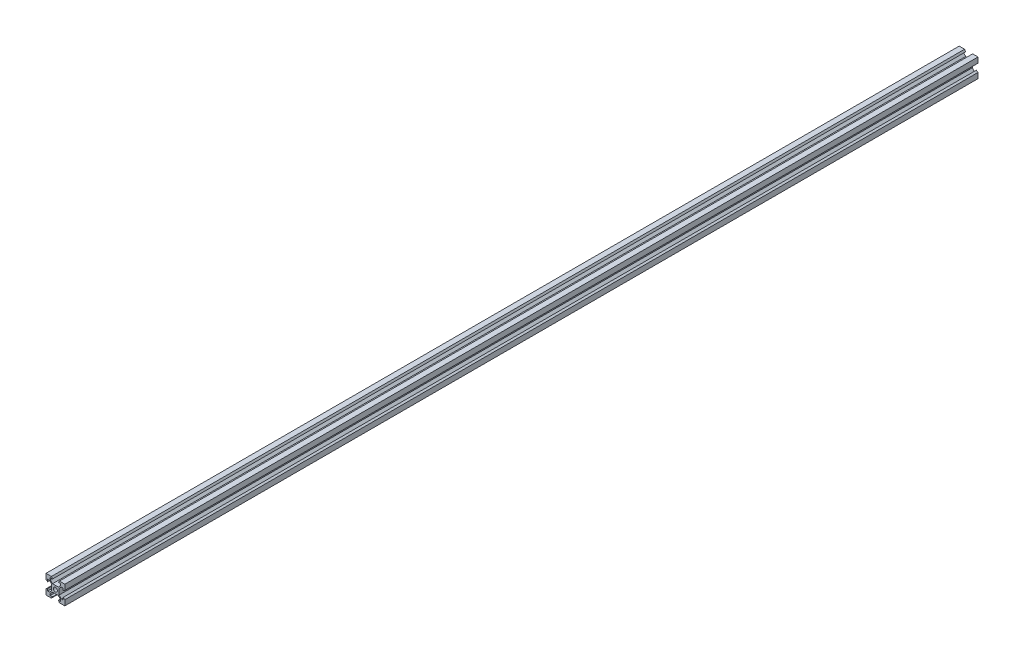
from build123d import *

# Parameters (mm, degrees)
SKETCH1_R           = 2.1
BOSS_EXTRUDE1_DEPTH = 970


with BuildPart() as part:
    # Sketch1 → Boss-Extrude1 (new body)
    with BuildSketch(Plane.XY):
        Polygon((-10, 10), (-4.25, 10), (-3.065, 8.2), (-5.5, 8.2), (-5.5, 6.348528137), (-3.051471863, 3.9), (0, 3.9), (3.051471863, 3.9), (5.5, 6.348528137), (5.5, 8.2), (3.065, 8.2), (4.25, 10), (10, 10), (10, 4.25), (8.2, 3.065), (8.2, 5.5), (6.348528137, 5.5), (3.9, 3.051471863), (3.9, 0), (3.9, -3.051471863), (6.348528137, -5.5), (8.2, -5.5), (8.2, -3.065), (10, -4.25), (10, -10), (4.25, -10), (3.065, -8.2), (5.5, -8.2), (5.5, -6.348528137), (3.051471863, -3.9), (0, -3.9), (-3.051471863, -3.9), (-5.5, -6.348528137), (-5.5, -8.2), (-3.065, -8.2), (-4.25, -10), (-10, -10), (-10, -4.25), (-8.2, -3.065), (-8.2, -5.5), (-6.348528137, -5.5), (-3.9, -3.051471863), (-3.9, 0), (-3.9, 3.051471863), (-6.348528137, 5.5), (-8.2, 5.5), (-8.2, 3.065), (-10, 4.25), align=None)
        Circle(SKETCH1_R, mode=Mode.SUBTRACT)
    extrude(amount=BOSS_EXTRUDE1_DEPTH)


solid = part.part
